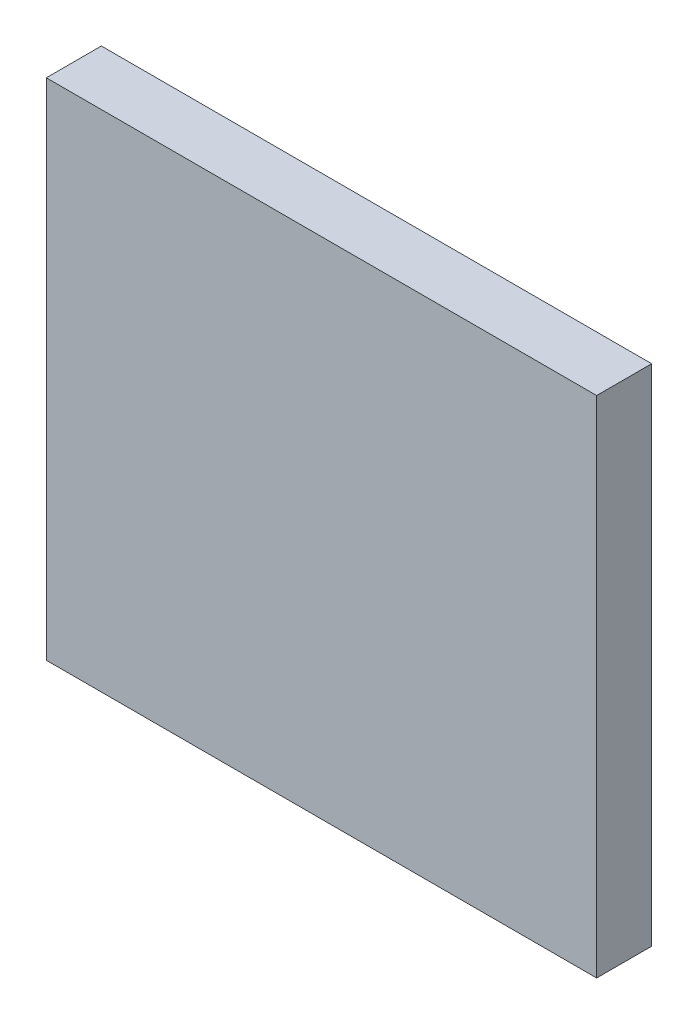
from build123d import *

# Parameters (mm, degrees)
SKETCH1_W           = 60
SKETCH1_H           = 55
BOSS_EXTRUDE1_DEPTH = 6


with BuildPart() as part:
    # Sketch1 → Boss-Extrude1 (new body)
    with BuildSketch(Plane.XY):
        with Locations((0, -7.783990534)):
            Rectangle(SKETCH1_W, SKETCH1_H)
    extrude(amount=BOSS_EXTRUDE1_DEPTH)


solid = part.part
